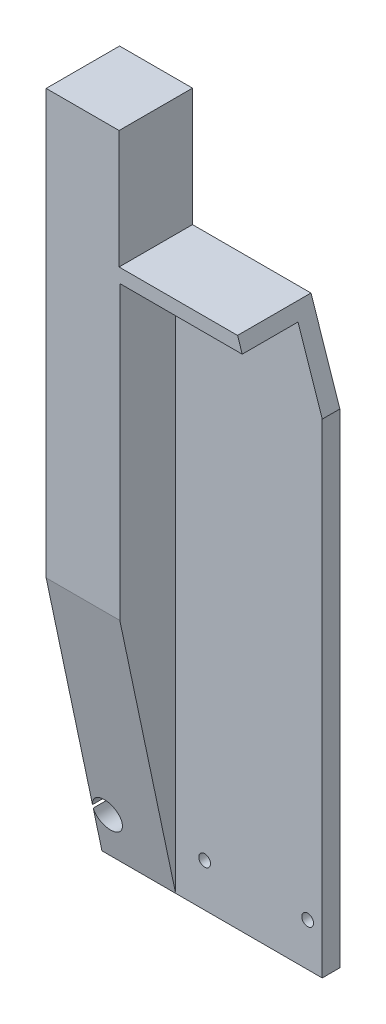
from build123d import *

# Parameters (mm, degrees)
SKETCH1_R           = 2
BOSS_EXTRUDE1_DEPTH = 6
BOSS_EXTRUDE2_DEPTH = 25
CUT_EXTRUDE1_DEPTH  = 26


with BuildPart() as part:
    # Sketch1 → Boss-Extrude1 (new body)
    with BuildSketch(Plane.XY):
        with BuildLine():
            ThreePointArc((-37.5, -101.931361022), (-27.5324139, -102.499769625), (-37.5, -103.068178229))
            Line((-37.5, -103.068178229), (-37.5, -117.1625))
            Line((-37.5, -117.1625), (37.5, -117.1625))
            Line((37.5, -117.1625), (37.5, 47.631763907))
            Line((37.5, 47.631763907), (27.667562569, 76.912960749))
            Line((27.667562569, 76.912960749), (-12.666, 76.912960749))
            Line((-12.666, 76.912960749), (-12.666, 117.1625))
            Line((-12.666, 117.1625), (-37.5, 117.1625))
            Line((-37.5, 117.1625), (-37.5, -101.931361022))
        make_face()
        with Locations((32.5324139, -102.503947692)):
            Circle(SKETCH1_R, mode=Mode.SUBTRACT)
        with Locations((-2.542, -102.503947692)):
            Circle(SKETCH1_R, mode=Mode.SUBTRACT)
    extrude(amount=BOSS_EXTRUDE1_DEPTH)

    # Sketch1_4 → Boss-Extrude2 (add)
    with BuildSketch(Plane.XY):
        with BuildLine():
            ThreePointArc((-37.5, -101.931361022), (-27.5324139, -102.499769625), (-37.5, -103.068178229))
            Line((-37.5, -103.068178229), (-37.5, -117.1625))
            Line((-37.5, -117.1625), (-12.416, -117.1625))
            Line((-12.416, -117.1625), (-12.416, 72.162960749))
            Line((-12.416, 72.162960749), (29.262581996, 72.162960749))
            Line((29.262581996, 72.162960749), (27.667562569, 76.912960749))
            Line((27.667562569, 76.912960749), (-12.666, 76.912960749))
            Line((-12.666, 76.912960749), (-12.666, 117.1625))
            Line((-12.666, 117.1625), (-37.5, 117.1625))
            Line((-37.5, 117.1625), (-37.5, -101.931361022))
        make_face()
    extrude(amount=BOSS_EXTRUDE2_DEPTH)

    # Sketch2 → Cut-Extrude1 (cut)
    with BuildSketch(Plane(origin=(-12.416, 0, 0), x_dir=(0, 0, -1), z_dir=(1, 0, 0))):
        Polygon((-25, -27.1625), (-6, -117.1625), (-25, -117.1625), align=None)
    extrude(amount=-CUT_EXTRUDE1_DEPTH, mode=Mode.SUBTRACT)


solid = part.part
